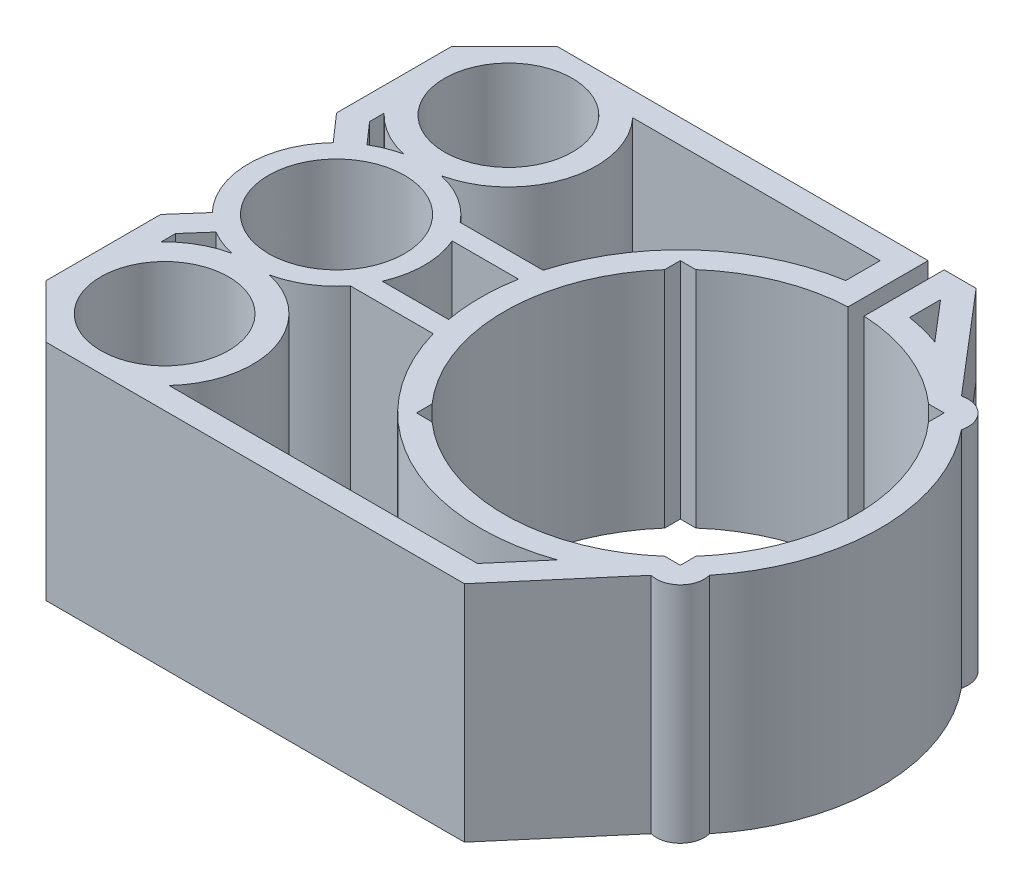
from build123d import *

# Parameters (mm, degrees)
SKETCH1_R           = 8
SKETCH1_R_2         = 8.5
BOSS_EXTRUDE1_DEPTH = 28
BOSS_EXTRUDE3_DEPTH = 12
CUT_EXTRUDE1_DEPTH  = 14.407172
SKETCH7_R           = 8.5
BOSS_EXTRUDE4_DEPTH = 15
SKETCH7_3_R         = 5
CUT_EXTRUDE2_DEPTH  = 15
SKETCH7_4_R         = 6.165
CUT_EXTRUDE3_DEPTH  = 1.5
SKETCH7_5_R         = 1.425
CUT_EXTRUDE4_DEPTH  = 8


with BuildPart() as part:
    # Sketch1 → Boss-Extrude1 (new body)
    with BuildSketch(Plane(origin=(0, 0, 0), x_dir=(1, 0, 0), z_dir=(0, 1, 0))):
        with BuildLine():
            ThreePointArc((-50.982546594, 7.568285795), (-54, 0), (-50.982546594, -7.568285795))
            Line((-50.982546594, -7.568285795), (-54, -11))
            Line((-54, -11), (-54, -25.34082208))
            Line((-54, -25.34082208), (-47.34082208, -32))
            Line((-47.34082208, -32), (5, -32))
            Line((5, -32), (15.759494281, -19.407172386))
            ThreePointArc((15.759494281, -19.407172386), (18.621320344, -18.621320344), (19.407172386, -15.759494281))
            ThreePointArc((19.407172386, -15.759494281), (25, 0), (19.407172386, 15.759494281))
            ThreePointArc((19.407172386, 15.759494281), (18.621320344, 18.621320344), (15.759494281, 19.407172386))
            Line((15.759494281, 19.407172386), (5, 32))
            Line((5, 32), (1, 32))
            Line((1, 32), (1, 21.977260976))
            ThreePointArc((1, 21.977260976), (8.243992543, 20.396974946), (14.551632211, 16.5))
            Line((14.551632211, 16.5), (16.5, 16.5))
            Line((16.5, 16.5), (16.5, 14.551632211))
            ThreePointArc((16.5, 14.551632211), (22, 0), (16.5, -14.551632211))
            Line((16.5, -14.551632211), (16.5, -16.5))
            Line((16.5, -16.5), (14.551632211, -16.5))
            ThreePointArc((14.551632211, -16.5), (0, -22), (-14.551632211, -16.5))
            Line((-14.551632211, -16.5), (-16.5, -16.5))
            Line((-16.5, -16.5), (-16.5, -14.551632211))
            ThreePointArc((-16.5, -14.551632211), (-22, 0), (-16.5, 14.551632211))
            Line((-16.5, 14.551632211), (-16.5, 16.5))
            Line((-16.5, 16.5), (-14.551632211, 16.5))
            ThreePointArc((-14.551632211, 16.5), (-8.243992543, 20.396974946), (-1, 21.977260976))
            Line((-1, 21.977260976), (-1, 32))
            Line((-1, 32), (-47.34082208, 32))
            Line((-47.34082208, 32), (-54, 25.34082208))
            Line((-54, 25.34082208), (-54, 11))
            Line((-54, 11), (-50.982546594, 7.568285795))
        make_face()
        with BuildLine():
            ThreePointArc((-48.638105805, -9.445197877), (-47.038026147, -10.232025451), (-45.331844763, -10.75))
            ThreePointArc((-45.331844763, -10.75), (-48.408051309, -11.921222362), (-51, -13.950165565))
            Line((-51, -13.950165565), (-51, -12.131352314))
            Line((-51, -12.131352314), (-48.638105805, -9.445197877))
        make_face(mode=Mode.SUBTRACT)
        with Locations((-43, -21.5)):
            Circle(SKETCH1_R, mode=Mode.SUBTRACT)
        with BuildLine():
            ThreePointArc((-34.95326153, -29), (-32.502649264, -18.212808567), (-40.668155237, -10.75))
            ThreePointArc((-40.668155237, -10.75), (-37.204464997, -9.349426401), (-34.409357086, -6.870287791))
            Line((-34.409357086, -6.870287791), (-24.037452978, -6.870287791))
            ThreePointArc((-24.037452978, -6.870287791), (-11.513133706, -22.191163833), (8.224630177, -23.60837687))
            Line((8.224630177, -23.60837687), (3.617949295, -29))
            Line((3.617949295, -29), (-34.95326153, -29))
        make_face(mode=Mode.SUBTRACT)
        with Locations((-43, 0)):
            Circle(SKETCH1_R_2, mode=Mode.SUBTRACT)
        with BuildLine():
            ThreePointArc((-45.331844763, 10.75), (-47.038026147, 10.232025451), (-48.638105805, 9.445197877))
            Line((-48.638105805, 9.445197877), (-51, 12.131352314))
            Line((-51, 12.131352314), (-51, 13.950165565))
            ThreePointArc((-51, 13.950165565), (-48.408051309, 11.921222362), (-45.331844763, 10.75))
        make_face(mode=Mode.SUBTRACT)
        with BuildLine():
            ThreePointArc((-32.905418056, -4.370287791), (-32, 0), (-32.905418056, 4.370287791))
            Line((-32.905418056, 4.370287791), (-24.615047931, 4.370287791))
            ThreePointArc((-24.615047931, 4.370287791), (-25, 0), (-24.615047931, -4.370287791))
            Line((-24.615047931, -4.370287791), (-32.905418056, -4.370287791))
        make_face(mode=Mode.SUBTRACT)
        with Locations((-43, 21.5)):
            Circle(SKETCH1_R, mode=Mode.SUBTRACT)
        with BuildLine():
            ThreePointArc((-34.409357086, 6.870287791), (-37.204464997, 9.349426401), (-40.668155237, 10.75))
            ThreePointArc((-40.668155237, 10.75), (-32.502649264, 18.212808567), (-34.95326153, 29))
            Line((-34.95326153, 29), (-4, 29))
            Line((-4, 29), (-4, 24.677925359))
            ThreePointArc((-4, 24.677925359), (-16.607308069, 18.68682206), (-24.037452978, 6.870287791))
            Line((-24.037452978, 6.870287791), (-34.409357086, 6.870287791))
        make_face(mode=Mode.SUBTRACT)
        with BuildLine():
            ThreePointArc((8.223751321, 23.608683026), (6.135213434, 24.235493725), (4, 24.677925359))
            Line((4, 24.677925359), (4, 28.552128404))
            Line((4, 28.552128404), (8.223751321, 23.608683026))
        make_face(mode=Mode.SUBTRACT)
    extrude(amount=BOSS_EXTRUDE1_DEPTH)

    # Sketch6 → Boss-Extrude3 (add)
    with BuildSketch(Plane(origin=(0, 20, 0), x_dir=(0, 0, -1), z_dir=(0, -1, 0))):
        Polygon((30.717367885, 3.963704263), (22.785433959, 3.963704263), (22.785433959, 10.604126234), align=None)
    extrude(amount=BOSS_EXTRUDE3_DEPTH)

    # Sketch3 → Cut-Extrude1 (cut)
    with BuildSketch(Plane.ZY.offset(-19.407172386)):
        with BuildLine():
            ThreePointArc((-23, 14), (-24.171572875, 16.828427125), (-27, 18))
            Line((-27, 18), (-27, 10))
            ThreePointArc((-27, 10), (-24.171572875, 11.171572875), (-23, 14))
        make_face()
        with BuildLine():
            Line((-27, 10), (-27, 18))
            ThreePointArc((-27, 18), (-31, 14), (-27, 10))
        make_face()
        with BuildLine():
            Line((-27, 18), (-32, 18))
            Line((-32, 18), (-32, 10))
            Line((-32, 10), (-27, 10))
            ThreePointArc((-27, 10), (-31, 14), (-27, 18))
        make_face()
    extrude(amount=CUT_EXTRUDE1_DEPTH, mode=Mode.SUBTRACT)

    # Sketch7 → Boss-Extrude4 (add)
    with BuildSketch(Plane.XZ):
        with Locations((-43, 0)):
            Circle(SKETCH7_R)
    extrude(amount=-BOSS_EXTRUDE4_DEPTH)

    # Sketch7_3 → Cut-Extrude2 (cut)
    with BuildSketch(Plane.XZ):
        with Locations((-43, 0)):
            Circle(SKETCH7_3_R)
    extrude(amount=-CUT_EXTRUDE2_DEPTH, mode=Mode.SUBTRACT)

    # Sketch7_4 → Cut-Extrude3 (cut)
    with BuildSketch(Plane.XZ):
        with Locations((-43, 0)):
            Circle(SKETCH7_4_R)
    extrude(amount=-CUT_EXTRUDE3_DEPTH, mode=Mode.SUBTRACT)

    # Sketch7_5 → Cut-Extrude4 (cut)
    with BuildSketch(Plane.XZ):
        with Locations((-48.64603005, -5.667657777)):
            Circle(SKETCH7_5_R)
        with Locations((-48.656854249, 5.656854249)):
            Circle(SKETCH7_5_R)
        with Locations((-37.332342223, 5.667678449)):
            Circle(SKETCH7_5_R)
        with Locations((-37.321518023, -5.656833577)):
            Circle(SKETCH7_5_R)
    extrude(amount=-CUT_EXTRUDE4_DEPTH, mode=Mode.SUBTRACT)


solid = part.part
